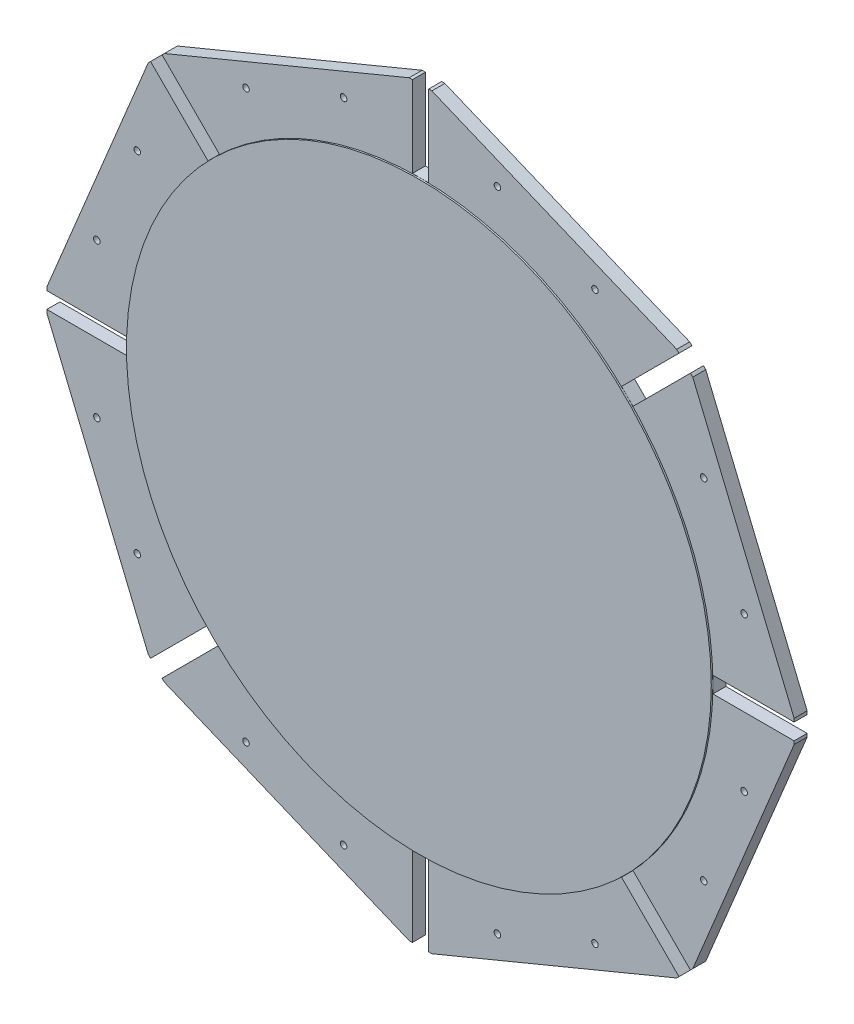
from build123d import *

# Parameters (mm, degrees)
BOSS_EXTRUDE1_DEPTH = 8
SKETCH2_R           = 180
BOSS_EXTRUDE2_DEPTH = 1
CUT_EXTRUDE1_REACH  = 10
SKETCH3_R           = 2


with BuildPart() as part:
    # Sketch1 → Boss-Extrude1 (new body)
    with BuildSketch(Plane.XY):
        Polygon((5, 230), (5, 180), (-5, 180), (-5, 230), (-7, 230), (-157.684812205, 167.584307141), (-159.099025767, 166.170093579), (-123.743686708, 130.814754519), (-130.81475452, 123.743686708), (-166.170093579, 159.099025767), (-167.584307141, 157.684812205), (-230, 7), (-230, 5), (-180, 5), (-180, -5), (-230, -5), (-230, -7), (-167.584307141, -157.684812205), (-166.170093579, -159.099025767), (-130.81475452, -123.743686708), (-123.743686708, -130.81475452), (-159.099025767, -166.170093579), (-157.684812205, -167.584307141), (-7, -230), (-5, -230), (-5, -180), (5, -180), (5, -230), (7, -230), (157.684812205, -167.584307141), (159.099025767, -166.170093579), (123.743686708, -130.814754519), (130.81475452, -123.743686708), (166.170093579, -159.099025767), (167.584307141, -157.684812205), (230, -7), (230, -5), (180, -5), (180, 5), (230, 5), (230, 7), (167.584307141, 157.684812205), (166.170093579, 159.099025767), (130.81475452, 123.743686708), (123.743686708, 130.81475452), (159.099025767, 166.170093579), (157.684812205, 167.584307141), (7, 230), align=None)
    extrude(amount=BOSS_EXTRUDE1_DEPTH)

    # Sketch2 → Boss-Extrude2 (add)
    with BuildSketch(Plane.XY.offset(8)):
        Circle(SKETCH2_R)
    extrude(amount=BOSS_EXTRUDE2_DEPTH)

    # Sketch3 → Cut-Extrude1 (cut, up to next)
    with BuildSketch(Plane.XY.offset(8), mode=Mode.PRIVATE) as cut_extrude1_sk1:
        with Locations((107.397750993, 174.354514299)):
            Circle(SKETCH3_R)
    cut_extrude1_tool1 = extrude(cut_extrude1_sk1.sketch, amount=-CUT_EXTRUDE1_REACH, mode=Mode.PRIVATE) & part.part
    add(cut_extrude1_tool1.solids().sort_by_distance((107.397751, 174.354514, 8))[0], mode=Mode.SUBTRACT)
    # Sketch3 → Cut-Extrude1 (cut, up to next)
    with BuildSketch(Plane.XY.offset(8), mode=Mode.PRIVATE) as cut_extrude1_sk2:
        with Locations((47.34558138, 199.228937402)):
            Circle(SKETCH3_R)
    cut_extrude1_tool2 = extrude(cut_extrude1_sk2.sketch, amount=-CUT_EXTRUDE1_REACH, mode=Mode.PRIVATE) & part.part
    add(cut_extrude1_tool2.solids().sort_by_distance((47.345581, 199.228937, 8))[0], mode=Mode.SUBTRACT)
    # Sketch3 → Cut-Extrude1 (cut, up to next)
    with BuildSketch(Plane.XY.offset(8), mode=Mode.PRIVATE) as cut_extrude1_sk3:
        with Locations((199.228937402, 47.34558138)):
            Circle(SKETCH3_R)
    cut_extrude1_tool3 = extrude(cut_extrude1_sk3.sketch, amount=-CUT_EXTRUDE1_REACH, mode=Mode.PRIVATE) & part.part
    add(cut_extrude1_tool3.solids().sort_by_distance((199.228937, 47.345581, 8))[0], mode=Mode.SUBTRACT)
    # Sketch3 → Cut-Extrude1 (cut, up to next)
    with BuildSketch(Plane.XY.offset(8), mode=Mode.PRIVATE) as cut_extrude1_sk4:
        with Locations((174.354514299, 107.397750993)):
            Circle(SKETCH3_R)
    cut_extrude1_tool4 = extrude(cut_extrude1_sk4.sketch, amount=-CUT_EXTRUDE1_REACH, mode=Mode.PRIVATE) & part.part
    add(cut_extrude1_tool4.solids().sort_by_distance((174.354514, 107.397751, 8))[0], mode=Mode.SUBTRACT)
    # Sketch3 → Cut-Extrude1 (cut, up to next)
    with BuildSketch(Plane.XY.offset(8), mode=Mode.PRIVATE) as cut_extrude1_sk5:
        with Locations((174.354514299, -107.397750993)):
            Circle(SKETCH3_R)
    cut_extrude1_tool5 = extrude(cut_extrude1_sk5.sketch, amount=-CUT_EXTRUDE1_REACH, mode=Mode.PRIVATE) & part.part
    add(cut_extrude1_tool5.solids().sort_by_distance((174.354514, -107.397751, 8))[0], mode=Mode.SUBTRACT)
    # Sketch3 → Cut-Extrude1 (cut, up to next)
    with BuildSketch(Plane.XY.offset(8), mode=Mode.PRIVATE) as cut_extrude1_sk6:
        with Locations((199.228937402, -47.34558138)):
            Circle(SKETCH3_R)
    cut_extrude1_tool6 = extrude(cut_extrude1_sk6.sketch, amount=-CUT_EXTRUDE1_REACH, mode=Mode.PRIVATE) & part.part
    add(cut_extrude1_tool6.solids().sort_by_distance((199.228937, -47.345581, 8))[0], mode=Mode.SUBTRACT)
    # Sketch3 → Cut-Extrude1 (cut, up to next)
    with BuildSketch(Plane.XY.offset(8), mode=Mode.PRIVATE) as cut_extrude1_sk7:
        with Locations((47.34558138, -199.228937402)):
            Circle(SKETCH3_R)
    cut_extrude1_tool7 = extrude(cut_extrude1_sk7.sketch, amount=-CUT_EXTRUDE1_REACH, mode=Mode.PRIVATE) & part.part
    add(cut_extrude1_tool7.solids().sort_by_distance((47.345581, -199.228937, 8))[0], mode=Mode.SUBTRACT)
    # Sketch3 → Cut-Extrude1 (cut, up to next)
    with BuildSketch(Plane.XY.offset(8), mode=Mode.PRIVATE) as cut_extrude1_sk8:
        with Locations((107.397750993, -174.354514299)):
            Circle(SKETCH3_R)
    cut_extrude1_tool8 = extrude(cut_extrude1_sk8.sketch, amount=-CUT_EXTRUDE1_REACH, mode=Mode.PRIVATE) & part.part
    add(cut_extrude1_tool8.solids().sort_by_distance((107.397751, -174.354514, 8))[0], mode=Mode.SUBTRACT)
    # Sketch3 → Cut-Extrude1 (cut, up to next)
    with BuildSketch(Plane.XY.offset(8), mode=Mode.PRIVATE) as cut_extrude1_sk9:
        with Locations((-107.397750993, -174.354514299)):
            Circle(SKETCH3_R)
    cut_extrude1_tool9 = extrude(cut_extrude1_sk9.sketch, amount=-CUT_EXTRUDE1_REACH, mode=Mode.PRIVATE) & part.part
    add(cut_extrude1_tool9.solids().sort_by_distance((-107.397751, -174.354514, 8))[0], mode=Mode.SUBTRACT)
    # Sketch3 → Cut-Extrude1 (cut, up to next)
    with BuildSketch(Plane.XY.offset(8), mode=Mode.PRIVATE) as cut_extrude1_sk10:
        with Locations((-47.34558138, -199.228937402)):
            Circle(SKETCH3_R)
    cut_extrude1_tool10 = extrude(cut_extrude1_sk10.sketch, amount=-CUT_EXTRUDE1_REACH, mode=Mode.PRIVATE) & part.part
    add(cut_extrude1_tool10.solids().sort_by_distance((-47.345581, -199.228937, 8))[0], mode=Mode.SUBTRACT)
    # Sketch3 → Cut-Extrude1 (cut, up to next)
    with BuildSketch(Plane.XY.offset(8), mode=Mode.PRIVATE) as cut_extrude1_sk11:
        with Locations((-199.228937402, -47.34558138)):
            Circle(SKETCH3_R)
    cut_extrude1_tool11 = extrude(cut_extrude1_sk11.sketch, amount=-CUT_EXTRUDE1_REACH, mode=Mode.PRIVATE) & part.part
    add(cut_extrude1_tool11.solids().sort_by_distance((-199.228937, -47.345581, 8))[0], mode=Mode.SUBTRACT)
    # Sketch3 → Cut-Extrude1 (cut, up to next)
    with BuildSketch(Plane.XY.offset(8), mode=Mode.PRIVATE) as cut_extrude1_sk12:
        with Locations((-174.354514299, -107.397750993)):
            Circle(SKETCH3_R)
    cut_extrude1_tool12 = extrude(cut_extrude1_sk12.sketch, amount=-CUT_EXTRUDE1_REACH, mode=Mode.PRIVATE) & part.part
    add(cut_extrude1_tool12.solids().sort_by_distance((-174.354514, -107.397751, 8))[0], mode=Mode.SUBTRACT)
    # Sketch3 → Cut-Extrude1 (cut, up to next)
    with BuildSketch(Plane.XY.offset(8), mode=Mode.PRIVATE) as cut_extrude1_sk13:
        with Locations((-174.354514299, 107.397750993)):
            Circle(SKETCH3_R)
    cut_extrude1_tool13 = extrude(cut_extrude1_sk13.sketch, amount=-CUT_EXTRUDE1_REACH, mode=Mode.PRIVATE) & part.part
    add(cut_extrude1_tool13.solids().sort_by_distance((-174.354514, 107.397751, 8))[0], mode=Mode.SUBTRACT)
    # Sketch3 → Cut-Extrude1 (cut, up to next)
    with BuildSketch(Plane.XY.offset(8), mode=Mode.PRIVATE) as cut_extrude1_sk14:
        with Locations((-199.228937402, 47.34558138)):
            Circle(SKETCH3_R)
    cut_extrude1_tool14 = extrude(cut_extrude1_sk14.sketch, amount=-CUT_EXTRUDE1_REACH, mode=Mode.PRIVATE) & part.part
    add(cut_extrude1_tool14.solids().sort_by_distance((-199.228937, 47.345581, 8))[0], mode=Mode.SUBTRACT)
    # Sketch3 → Cut-Extrude1 (cut, up to next)
    with BuildSketch(Plane.XY.offset(8), mode=Mode.PRIVATE) as cut_extrude1_sk15:
        with Locations((-47.34558138, 199.228937402)):
            Circle(SKETCH3_R)
    cut_extrude1_tool15 = extrude(cut_extrude1_sk15.sketch, amount=-CUT_EXTRUDE1_REACH, mode=Mode.PRIVATE) & part.part
    add(cut_extrude1_tool15.solids().sort_by_distance((-47.345581, 199.228937, 8))[0], mode=Mode.SUBTRACT)
    # Sketch3 → Cut-Extrude1 (cut, up to next)
    with BuildSketch(Plane.XY.offset(8), mode=Mode.PRIVATE) as cut_extrude1_sk16:
        with Locations((-107.397750993, 174.354514299)):
            Circle(SKETCH3_R)
    cut_extrude1_tool16 = extrude(cut_extrude1_sk16.sketch, amount=-CUT_EXTRUDE1_REACH, mode=Mode.PRIVATE) & part.part
    add(cut_extrude1_tool16.solids().sort_by_distance((-107.397751, 174.354514, 8))[0], mode=Mode.SUBTRACT)


solid = part.part
